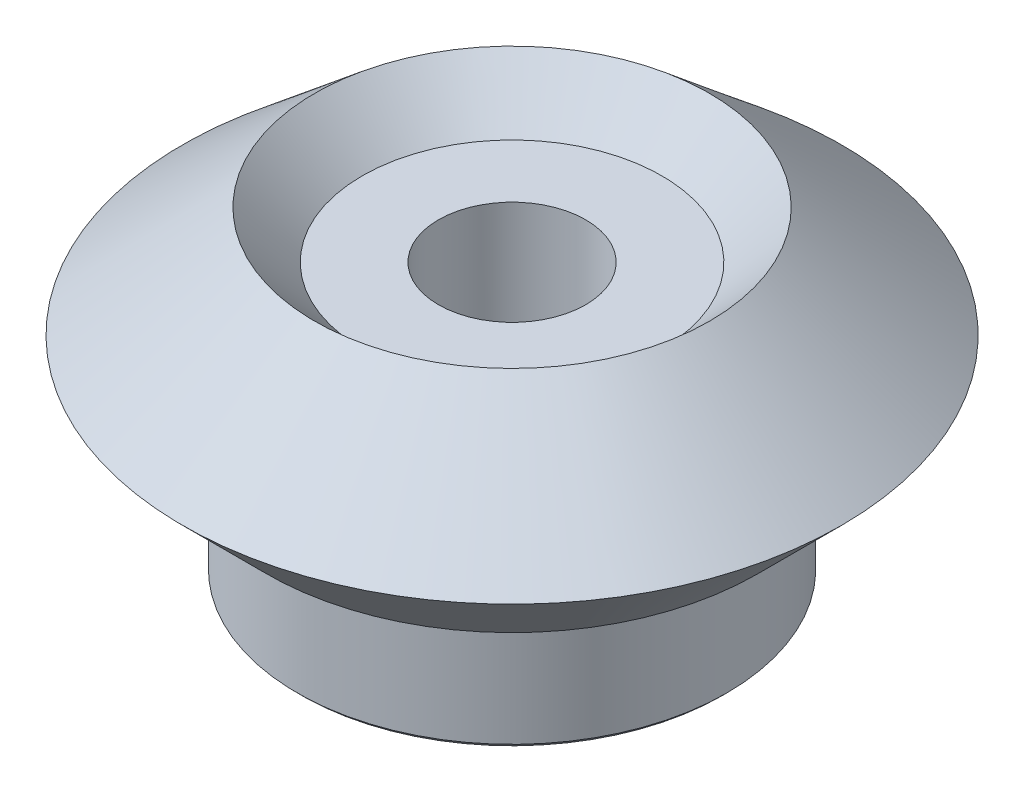
from build123d import *

# Parameters (mm, degrees)
SKETCH2_R          = 6
CUT_EXTRUDE1_DEPTH = 26.88


with BuildPart() as part:
    # Sketch1 → Revolve1 (revolve)
    with BuildSketch(Plane.XY.offset(40)):
        Polygon((5.353553391, 0), (17.146446609, 0), (17.5, 0.353553391), (17.5, 10), (19.995, 10), (26.855, 16.86), (16.085548044, 25.88), (12.205548044, 22), (5, 22), (5, 0.353553391), align=None)
    revolve(axis=Axis((0, 25.88, 40), (0, -1, 0)))

    # Sketch2 → Cut-Extrude1 (cut, through all)
    with BuildSketch(Plane.XZ):
        with Locations((0, 40)):
            Circle(SKETCH2_R)
    extrude(amount=-CUT_EXTRUDE1_DEPTH, mode=Mode.SUBTRACT)


solid = part.part
